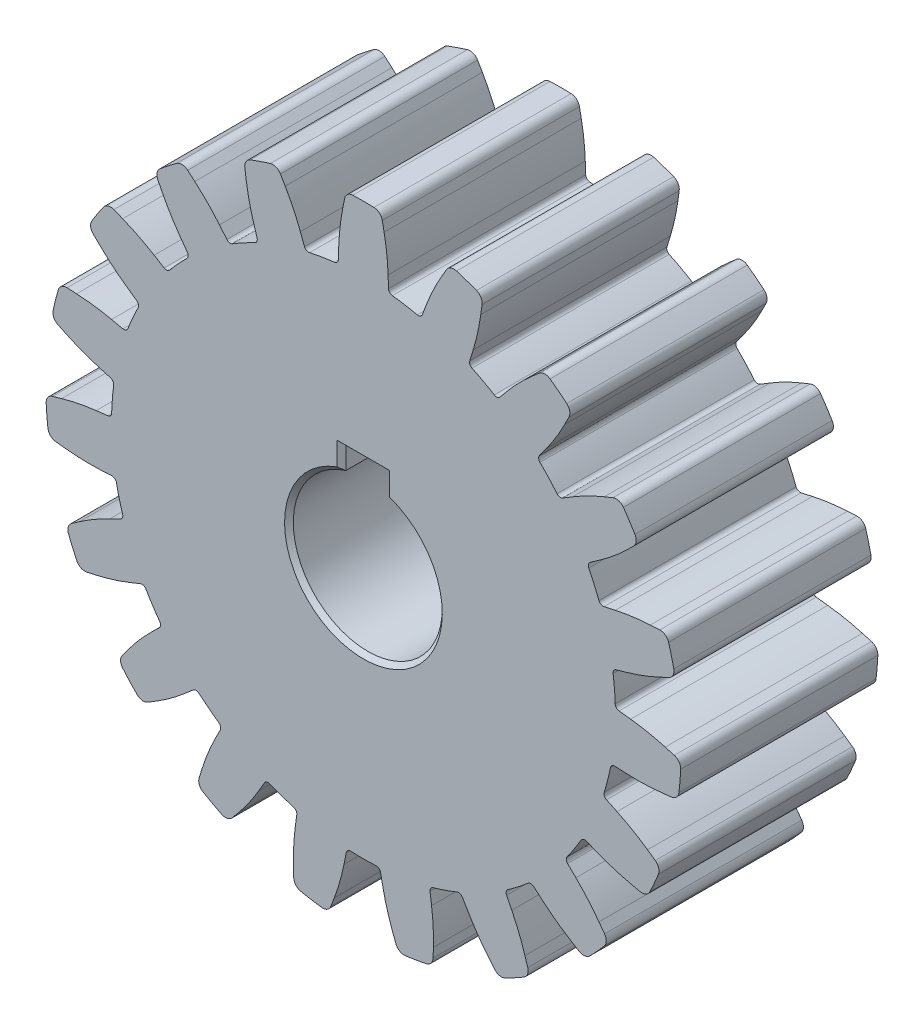
from build123d import *

# Parameters (mm, degrees)
BOSS_EXTRUDE1_DEPTH = 22.5
BOSS_EXTRUDE2_DEPTH = 22.5
CIRPATTERN1_COUNT   = 19
CHAMFER1_SIZE       = 1
FILLET1_R           = 1


with BuildPart() as part:
    # Sketch2 → Boss-Extrude1 (new, symmetric)
    with BuildSketch(Plane.XY):
        with BuildLine():
            ThreePointArc((5.75, 57.211777634), (0, 57.5), (-5.75, 57.211777634))
            ThreePointArc((-5.75, 57.211777634), (-38.572172612, -42.643141301), (57.5, 0))
            ThreePointArc((57.5, 0), (42.643141301, 38.572172612), (5.75, 57.211777634))
        make_face()
        with BuildLine():
            Line((-5, 16.248076809), (-5, 21.248076809))
            Line((-5, 21.248076809), (5, 21.248076809))
            Line((5, 21.248076809), (5, 16.248076809))
            ThreePointArc((5, 16.248076809), (0, -17), (-5, 16.248076809))
        make_face(mode=Mode.SUBTRACT)
    extrude(amount=BOSS_EXTRUDE1_DEPTH, both=True)

    # Sketch2_4 → Boss-Extrude2 (add, symmetric)
    with BuildSketch(Plane.XY):
        with BuildLine():
            Line((-5.633586888, 60.729834048), (-5.75, 57.211777634))
            ThreePointArc((-5.75, 57.211777634), (0, 57.5), (5.75, 57.211777634))
            Line((5.75, 57.211777634), (5.633586888, 60.729834048))
            ThreePointArc((5.633586888, 60.729834048), (5.338160254, 64.748410712), (4.720105194, 68.730149433))
            Line((4.720105194, 68.730149433), (4.303494882, 70.847274547))
            ThreePointArc((4.303494882, 70.847274547), (3.636975996, 71.98452794), (2.407543196, 72.460014738))
            ThreePointArc((2.407543196, 72.460014738), (0, 72.5), (-2.407543196, 72.460014738))
            ThreePointArc((-2.407543196, 72.460014738), (-3.636975996, 71.98452794), (-4.303494882, 70.847274547))
            Line((-4.303494882, 70.847274547), (-4.720105194, 68.730149433))
            ThreePointArc((-4.720105194, 68.730149433), (-5.338160254, 64.748410712), (-5.633586888, 60.729834048))
        make_face()
    boss_extrude2 = extrude(amount=BOSS_EXTRUDE2_DEPTH, both=True)

    # CirPattern1: Boss-Extrude2 ×19 about axis
    cirpattern1_axis = Axis((0, 0, 22.5), (0, 0, -1))
    for i in range(1, CIRPATTERN1_COUNT):
        add(boss_extrude2.rotate(cirpattern1_axis, i * 360 / CIRPATTERN1_COUNT))

    # Chamfer1
    chamfer1_edges = [part.edges().sort_by_distance(p)[0] for p in [
        (5, 18.748076809, -22.5),
        (0, 21.248076809, -22.5),
        (-5, 18.748076809, -22.5),
        (0, -17, -22.5),
        (5, 18.748076809, 22.5),
        (0, 21.248076809, 22.5),
        (-5, 18.748076809, 22.5),
        (0, -17, 22.5),
    ]]
    chamfer(chamfer1_edges, length=CHAMFER1_SIZE)

    # Fillet1
    fillet1_edges = [part.edges().sort_by_distance(p)[0] for p in [
        (24.01508297, 52.244863766, 0),
        (13.13818469, 55.978907662, 0),
        (-5.75, 57.211777634, 0),
        (5.75, 57.211777634, 0),
        (30.602643209, 48.679854443, 0),
        (39.677759067, 41.616408247, 0),
        (44.750830487, 36.10558365, 0),
        (51.040734306, 26.47816915, 0),
        (54.049570902, 19.618712632, 0),
        (56.872654004, 8.470609573, 0),
        (57.491201643, 1.005849684, 0),
        (56.541539171, -10.454871985, 0),
        (54.702768619, -17.716012683, 0),
        (50.083271236, -28.24740594, 0),
        (45.986441814, -34.518070185, 0),
        (38.19770374, -42.978895158, 0),
        (32.286770485, -47.579559179, 0),
        (22.172822346, -53.052954199, 0),
        (15.088326593, -55.485064663, 0),
        (3.745171604, -57.377902451, 0),
        (-3.745171604, -57.377902451, 0),
        (-15.088326593, -55.485064663, 0),
        (-22.172822346, -53.052954199, 0),
        (-32.286770485, -47.579559179, 0),
        (-38.19770374, -42.978895158, 0),
        (-45.986441814, -34.518070185, 0),
        (-50.083271236, -28.24740594, 0),
        (-54.702768619, -17.716012683, 0),
        (-56.541539171, -10.454871985, 0),
        (-57.491201643, 1.005849684, 0),
        (-56.872654004, 8.470609573, 0),
        (-54.049570902, 19.618712632, 0),
        (-51.040734306, 26.47816915, 0),
        (-44.750830487, 36.10558365, 0),
        (-39.677759067, 41.616408247, 0),
        (-30.602643209, 48.679854443, 0),
        (-24.01508297, 52.244863766, 0),
        (-13.13818469, 55.978907662, 0),
    ]]
    fillet(fillet1_edges, radius=FILLET1_R)


solid = part.part
